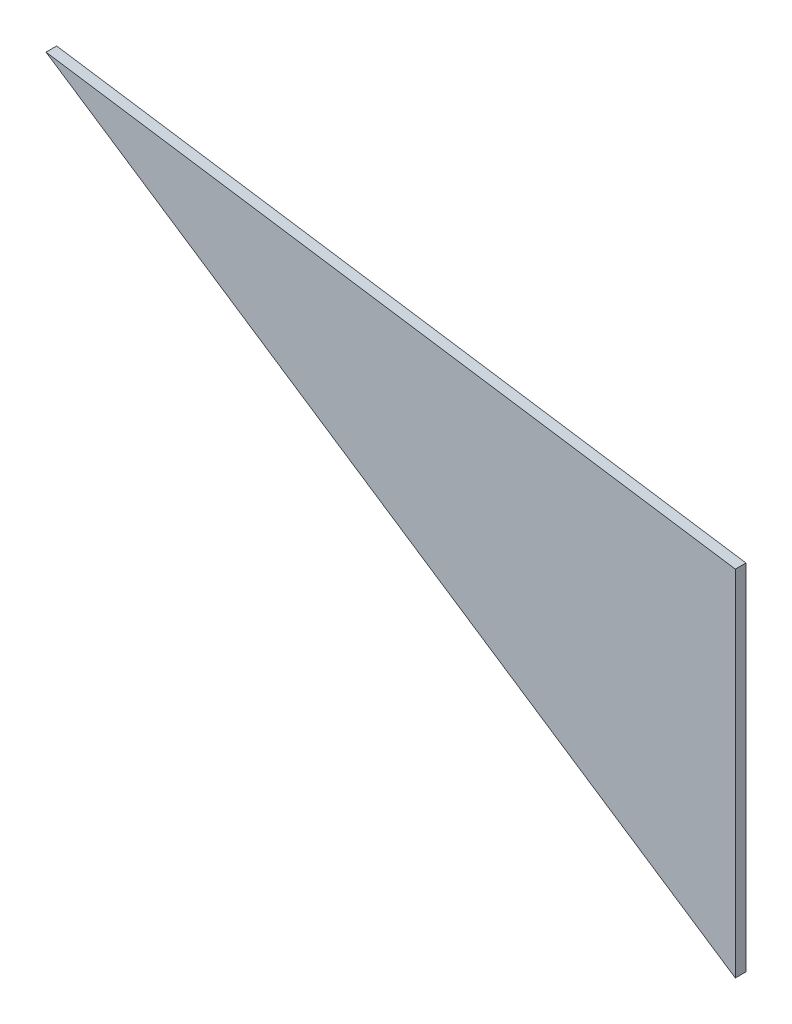
from build123d import *

# Parameters (mm, degrees)
DODANIE_WYCI_GNI_CIE1_DEPTH = 10


with BuildPart() as part:
    # Szkic1 → Dodanie-wyciągnięcie1 (new body)
    with BuildSketch(Plane.XY):
        Polygon((-210.680056235, 173.373216466), (-210.680056235, -159.825581885), (-859.317008092, 270.340623328), align=None)
    extrude(amount=DODANIE_WYCI_GNI_CIE1_DEPTH)


solid = part.part
